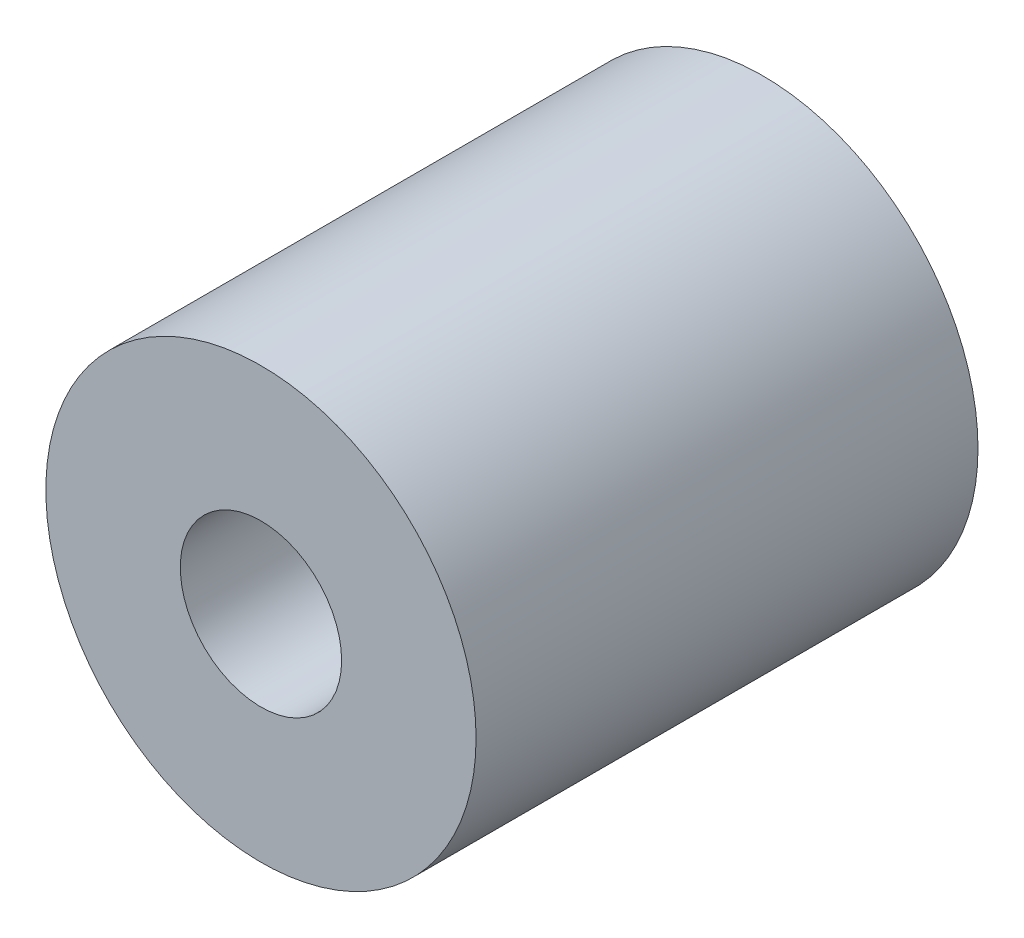
from build123d import *

# Parameters (mm, degrees)
SKETCH1_R      = 9.525
SKETCH1_R_2    = 3.571875
EXTRUDE1_DEPTH = 11.1125


with BuildPart() as part:
    # Sketch1 → Extrude1 (new body, symmetric)
    with BuildSketch(Plane.XY):
        Circle(SKETCH1_R)
        Circle(SKETCH1_R_2, mode=Mode.SUBTRACT)
    extrude(amount=EXTRUDE1_DEPTH, both=True)


solid = part.part
